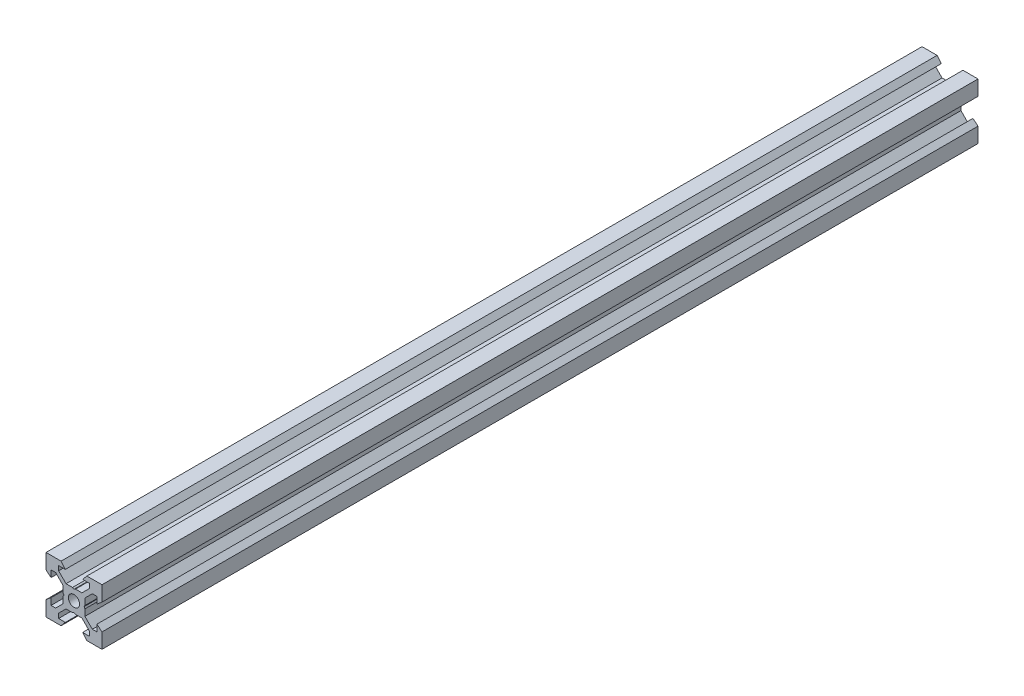
from build123d import *

# Parameters (mm, degrees)
SKETCH1_R           = 2
BOSS_EXTRUDE1_DEPTH = 156.525


with BuildPart() as part:
    # Sketch1 → Boss-Extrude1 (new body, symmetric)
    with BuildSketch(Plane.XY):
        Polygon((10, 10), (10, 4.610379336), (8.2, 3.1), (8.2, 5.5), (6.560660172, 5.5), (3.9, 2.839339828), (3.9, 0.519615242), (3.6, 0), (3.9, -0.519615242), (3.9, -2.839339828), (6.560660172, -5.5), (8.2, -5.5), (8.2, -3.1), (10, -4.610379336), (10, -10), (4.610379336, -10), (3.1, -8.2), (5.5, -8.2), (5.5, -6.560660172), (2.839339828, -3.9), (0.519615242, -3.9), (0, -3.6), (-0.519615242, -3.9), (-2.839339828, -3.9), (-5.5, -6.560660172), (-5.5, -8.2), (-3.1, -8.2), (-4.610379336, -10), (-10, -10), (-10, -4.610379336), (-8.2, -3.1), (-8.2, -5.5), (-6.560660172, -5.5), (-3.9, -2.839339828), (-3.9, -0.519615242), (-3.6, 0), (-3.9, 0.519615242), (-3.9, 2.839339828), (-6.560660172, 5.5), (-8.2, 5.5), (-8.2, 3.1), (-10, 4.610379336), (-10, 10), (-4.610379336, 10), (-3.1, 8.2), (-5.5, 8.2), (-5.5, 6.560660172), (-2.839339828, 3.9), (-0.519615242, 3.9), (0, 3.6), (0.519615242, 3.9), (2.839339828, 3.9), (5.5, 6.560660172), (5.5, 8.2), (3.1, 8.2), (4.610379336, 10), align=None)
        Circle(SKETCH1_R, mode=Mode.SUBTRACT)
    extrude(amount=BOSS_EXTRUDE1_DEPTH, both=True)


solid = part.part
